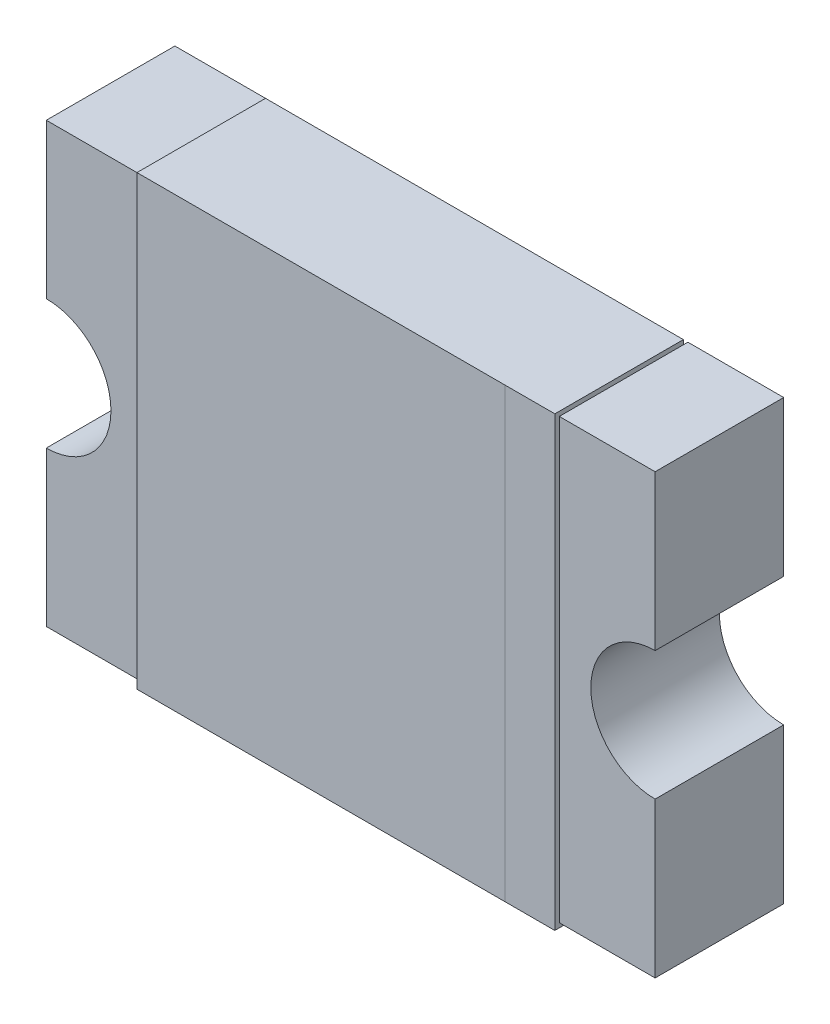
from build123d import *

# Parameters (mm, degrees)
ESQUISSE1_W             = 4.735
ESQUISSE1_H             = 3.41
EXTRUSION1_DEPTH        = 1
ESQUISSE2_R             = 0.5
ENL_V_MAT_EXTRU_1_DEPTH = 1
ESQUISSE4_R             = 0.502851751
ENL_V_MAT_EXTRU_2_DEPTH = 1
ESQUISSE8_W             = 3.25
ESQUISSE8_H             = 3.41
EXTRUSION3_DEPTH        = 0.035
ESQUISSE10_W            = 3.25
ESQUISSE10_H            = 1.035
EXTRUSION5_DEPTH        = 0.035
ESQUISSE11_W            = 3.25
ESQUISSE11_H            = 1.035
EXTRUSION6_DEPTH        = 0.035
ESQUISSE12_W            = 3.25
ESQUISSE12_H            = 3.48
ENL_V_MAT_EXTRU_6_DEPTH = 0.035
ESQUISSE13_W            = 0.388132222
ESQUISSE13_H            = 3.48
ENL_V_MAT_EXTRU_7_DEPTH = 0.0001


with BuildPart() as part:
    # Esquisse1 → Extrusion1 (new body)
    with BuildSketch(Plane.XY):
        with Locations((0.0025, 0)):
            Rectangle(ESQUISSE1_W, ESQUISSE1_H)
    extrude(amount=EXTRUSION1_DEPTH)

    # Esquisse2 → Enlèv. mat.-Extru.1 (cut)
    with BuildSketch(Plane(origin=(1.48, 0, 1), x_dir=(0, 1, 0), z_dir=(0, 0, -1))):
        with Locations((0, 0.89)):
            Circle(ESQUISSE2_R)
    extrude(amount=ENL_V_MAT_EXTRU_1_DEPTH, mode=Mode.SUBTRACT)

    # Esquisse4 → Enlèv. mat.-Extru.2 (cut)
    with BuildSketch(Plane.XY.offset(1)):
        with Locations((-2.365, 0)):
            Circle(ESQUISSE4_R)
    extrude(amount=-ENL_V_MAT_EXTRU_2_DEPTH, mode=Mode.SUBTRACT)

    # Esquisse8 → Extrusion3 (add)
    with BuildSketch(Plane.XY.offset(1)):
        Rectangle(ESQUISSE8_W, ESQUISSE8_H)
    extrude(amount=EXTRUSION3_DEPTH)

    # Esquisse10 → Extrusion5 (add)
    with BuildSketch(Plane(origin=(0, 1.705, 0), x_dir=(-1, 0, 0), z_dir=(0, 1, 0))):
        with Locations((0, 0.5175)):
            Rectangle(ESQUISSE10_W, ESQUISSE10_H)
    extrude(amount=EXTRUSION5_DEPTH)

    # Esquisse11 → Extrusion6 (add)
    with BuildSketch(Plane.XZ.offset(1.705)):
        with Locations((0, 0.5175)):
            Rectangle(ESQUISSE11_W, ESQUISSE11_H)
    extrude(amount=EXTRUSION6_DEPTH)

    # Esquisse12 → Enlèv. mat.-Extru.6 (cut)
    with BuildSketch(Plane(origin=(0, 0, 0), x_dir=(1, 0, 0), z_dir=(0, 0, -1))):
        Rectangle(ESQUISSE12_W, ESQUISSE12_H)
    extrude(amount=-ENL_V_MAT_EXTRU_6_DEPTH, mode=Mode.SUBTRACT)

    # Esquisse13 → Enlèv. mat.-Extru.7 (cut)
    with BuildSketch(Plane.XY.offset(1.035)):
        with Locations((1.430933889, 0)):
            Rectangle(ESQUISSE13_W, ESQUISSE13_H)
    extrude(amount=-ENL_V_MAT_EXTRU_7_DEPTH, mode=Mode.SUBTRACT)


solid = part.part
